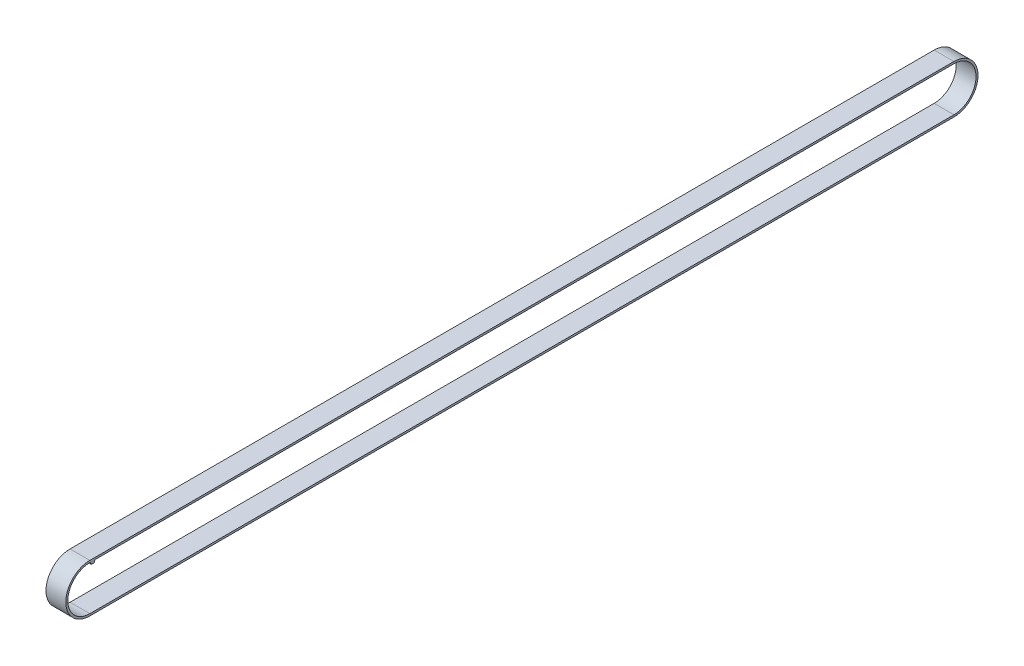
from build123d import *

# Parameters (mm, degrees)
BOSS_EXTRUDE1_DEPTH = 6
BOSS_EXTRUDE2_DEPTH = 6


with BuildPart() as part:
    # Sketch1 → Boss-Extrude1 (new body)
    with BuildSketch(Plane(origin=(0, 0, 0), x_dir=(0, 0, -1), z_dir=(1, 0, 0))):
        with BuildLine():
            Line((0, 7.3), (262, 7.3))
            ThreePointArc((262, 7.3), (269.3, 0), (262, -7.3))
            Line((262, -7.3), (0, -7.3))
            ThreePointArc((0, -7.3), (-7.3, 0), (0, 7.3))
        make_face()
        with BuildLine():
            Line((0, 6.7), (262, 6.7))
            ThreePointArc((262, 6.7), (268.7, 0), (262, -6.7))
            Line((262, -6.7), (0, -6.7))
            ThreePointArc((0, -6.7), (-6.7, 0), (0, 6.7))
        make_face(mode=Mode.SUBTRACT)
    extrude(amount=BOSS_EXTRUDE1_DEPTH)

    # Sketch2 → Boss-Extrude2 (add, through all)
    with BuildSketch(Plane(origin=(0, 0, 0), x_dir=(0, 0, -1), z_dir=(1, 0, 0))):
        with BuildLine():
            Line((0.187938524, 6.568404029), (0.346923655, 6.131595971))
            ThreePointArc((0.346923655, 6.131595971), (0.420146892, 6.036169591), (0.534862179, 6))
            Line((0.534862179, 6), (1.158985131, 6))
            ThreePointArc((1.158985131, 6), (1.273700418, 6.036169591), (1.346923655, 6.131595971))
            Line((1.346923655, 6.131595971), (1.505908786, 6.568404029))
            ThreePointArc((1.505908786, 6.568404029), (1.579132023, 6.663830409), (1.69384731, 6.7))
            Line((1.69384731, 6.7), (0, 6.7))
            ThreePointArc((0, 6.7), (0.114715287, 6.663830409), (0.187938524, 6.568404029))
        make_face()
    extrude(amount=BOSS_EXTRUDE2_DEPTH)


solid = part.part
